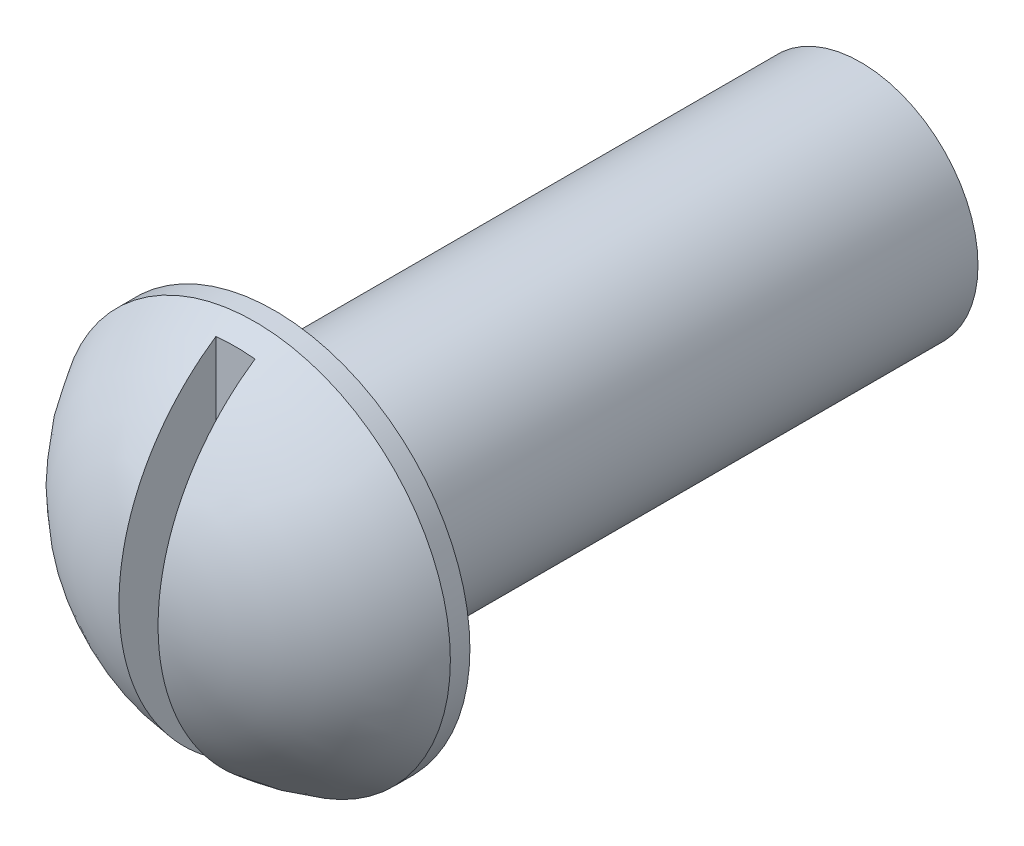
from build123d import *

# Parameters (mm, degrees)
SKETCH_1_R          = 0.3
EXTRUDE_1_DEPTH     = 1.5
SKETCH_2_R          = 0.5
SKETCH_2_R_2        = 0.3
EXTRUDE_2_DEPTH     = 0.05
DOME_1_FACE_RADIUS  = 0.5
DOME_1_HEIGHT       = 0.3
CUT_EXTRUDE_1_DEPTH = 3.12


with BuildPart() as part:
    # Sketch 1 → Extrude 1 (new body)
    with BuildSketch(Plane.XY):
        with Locations((-0.75, -2.383195553)):
            Circle(SKETCH_1_R)
    extrude(amount=EXTRUDE_1_DEPTH)

    # Sketch 2 → Extrude 2 (add)
    with BuildSketch(Plane.XY.offset(1.5)):
        with Locations((-0.75, -2.383195553)):
            Circle(SKETCH_2_R)
        with Locations((-0.75, -2.383195553)):
            Circle(SKETCH_2_R_2, mode=Mode.SUBTRACT)
        with Locations((-0.75, -2.383195553)):
            Circle(SKETCH_2_R_2)
    extrude(amount=EXTRUDE_2_DEPTH)

    # Dome 1: a dome of height H over a round flat face of radius A is a cap of a sphere of radius (A * A + H * H) / (2 * H)
    dome_1_r = (DOME_1_FACE_RADIUS * DOME_1_FACE_RADIUS + DOME_1_HEIGHT * DOME_1_HEIGHT) / (2 * DOME_1_HEIGHT)
    dome_1_base = Plane((-0.75, -2.383195553, 1.55), z_dir=(0, 0, 1))
    with Locations(dome_1_base.offset(DOME_1_HEIGHT - dome_1_r)):
        dome_1_ball = Sphere(dome_1_r, mode=Mode.PRIVATE)
    add(split(dome_1_ball, bisect_by=dome_1_base, keep=Keep.TOP, mode=Mode.PRIVATE))

    # Sketch 3 → Cut-Extrude 1 (cut)
    with BuildSketch(Plane(origin=(0, 0, 1.6), x_dir=(-1, 0, 0), z_dir=(0, 0, -1))):
        Polygon((0.8, -2.383195553), (0.8, -3.010764218), (0.7, -3.010764218), (0.7, -2.383195553), (0.7, -1.624183347), (0.8, -1.624183347), align=None)
    extrude(amount=-CUT_EXTRUDE_1_DEPTH, mode=Mode.SUBTRACT)


solid = part.part
